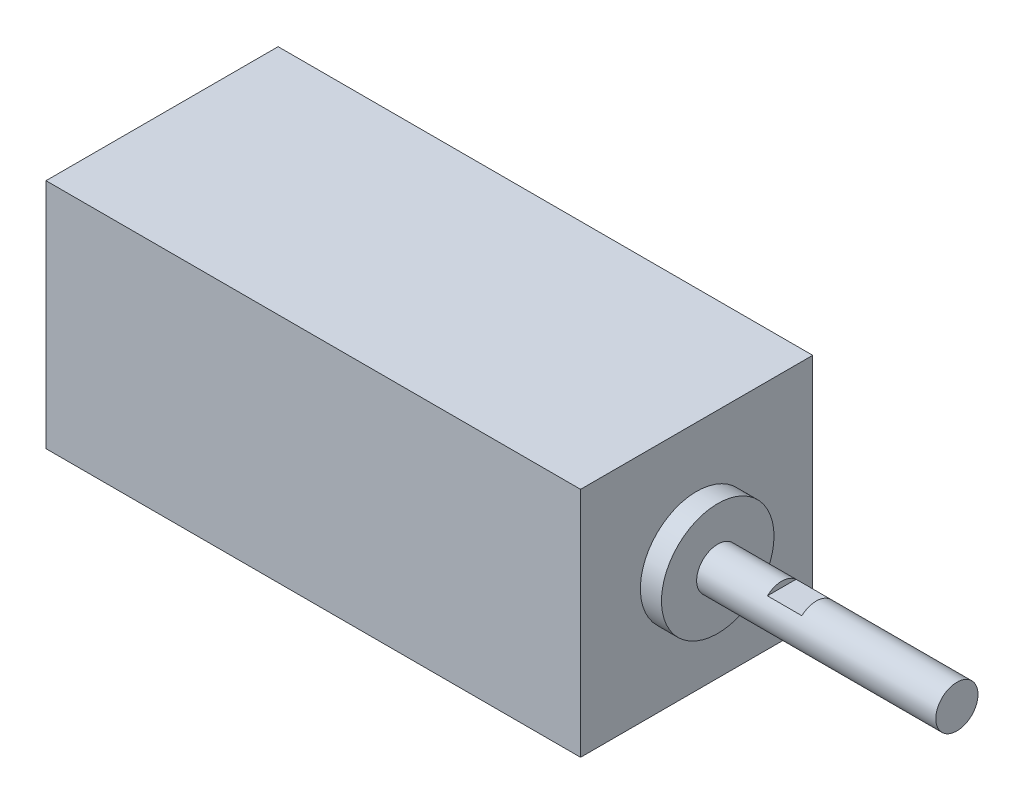
from build123d import *

# Parameters (mm, degrees)
SKETCH1_W           = 33
SKETCH1_H           = 33
BOSS_EXTRUDE1_DEPTH = 38
SKETCH2_R           = 8
BOSS_EXTRUDE2_DEPTH = 3
SKETCH3_R           = 3
BOSS_EXTRUDE3_DEPTH = 34
SKETCH4_W           = 4.9
SKETCH4_H           = 4.836057971
CUT_EXTRUDE1_DEPTH  = 17


with BuildPart() as part:
    # Sketch1 → Boss-Extrude1 (new body, symmetric)
    with BuildSketch(Plane(origin=(0, 0, 0), x_dir=(0, 0, -1), z_dir=(1, 0, 0))):
        Rectangle(SKETCH1_W, SKETCH1_H)
    extrude(amount=BOSS_EXTRUDE1_DEPTH, both=True)

    # Sketch2 → Boss-Extrude2 (add)
    with BuildSketch(Plane(origin=(38, 0, 0), x_dir=(0, 0, -1), z_dir=(1, 0, 0))):
        Circle(SKETCH2_R)
    extrude(amount=BOSS_EXTRUDE2_DEPTH)

    # Sketch3 → Boss-Extrude3 (add)
    with BuildSketch(Plane(origin=(41, 0, 0), x_dir=(0, 0, -1), z_dir=(1, 0, 0))):
        Circle(SKETCH3_R)
    extrude(amount=BOSS_EXTRUDE3_DEPTH)

    # Sketch4 → Cut-Extrude1 (cut, symmetric)
    with BuildSketch(Plane.XY):
        with Locations((52.55, 4.620557789)):
            Rectangle(SKETCH4_W, SKETCH4_H)
    extrude(amount=CUT_EXTRUDE1_DEPTH, both=True, mode=Mode.SUBTRACT)


solid = part.part
